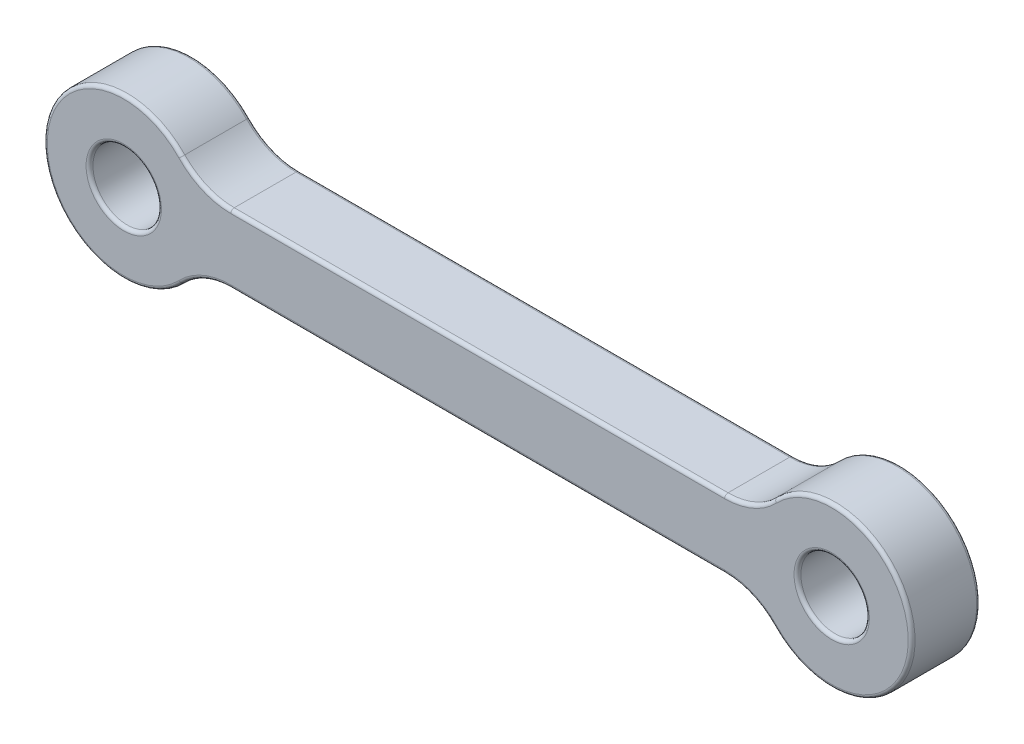
from build123d import *

# Parameters (mm, degrees)
SKETCH1_R           = 3.5
SKETCH1_R_2         = 1.5
BOSS_EXTRUDE1_DEPTH = 1.5
FILLET1_R           = 3
FILLET2_R           = 0.15


with BuildPart() as part:
    # Sketch1 → Boss-Extrude1 (new body, symmetric)
    with BuildSketch(Plane.XY):
        Circle(SKETCH1_R)
        Circle(SKETCH1_R_2, mode=Mode.SUBTRACT)
        with BuildLine():
            Line((3.16227766, -1.5), (27.83772234, -1.5))
            ThreePointArc((27.83772234, -1.5), (27.5, 0), (27.83772234, 1.5))
            Line((27.83772234, 1.5), (3.16227766, 1.5))
            ThreePointArc((3.16227766, 1.5), (3.414525722, 0.768774411), (3.5, 0))
            ThreePointArc((3.5, 0), (3.414525722, -0.768774411), (3.16227766, -1.5))
        make_face()
        with Locations((31, 0)):
            Circle(SKETCH1_R)
        with Locations((31, 0)):
            Circle(SKETCH1_R_2, mode=Mode.SUBTRACT)
    extrude(amount=BOSS_EXTRUDE1_DEPTH, both=True)

    # Fillet1
    fillet1_edges = [part.edges().sort_by_distance(p)[0] for p in [
        (3.16227766, 1.5, 0),
        (27.83772234, 1.5, 0),
        (27.83772234, -1.5, 0),
        (3.16227766, -1.5, 0),
    ]]
    fillet(fillet1_edges, radius=FILLET1_R)

    # Fillet2
    fillet2_edges = [part.edges().sort_by_distance(p)[0] for p in [
        (-1.5, 0, -1.5),
        (15.5, -1.5, -1.5),
        (15.5, -1.5, 1.5),
        (-3.5, 0, -1.5),
        (-3.5, 0, 1.5),
        (34.5, 0, -1.5),
        (34.5, 0, 1.5),
        (15.5, 1.5, -1.5),
        (15.5, 1.5, 1.5),
        (3.513718949, -1.740401367, -1.5),
        (3.513718949, -1.740401367, 1.5),
        (27.486281051, -1.740401367, -1.5),
        (29.5, 0, 1.5),
        (27.486281051, -1.740401367, 1.5),
        (3.513718949, 1.740401367, -1.5),
        (3.513718949, 1.740401367, 1.5),
        (27.486281051, 1.740401367, -1.5),
        (27.486281051, 1.740401367, 1.5),
        (-1.5, 0, 1.5),
        (29.5, 0, -1.5),
    ]]
    fillet(fillet2_edges, radius=FILLET2_R)


solid = part.part
